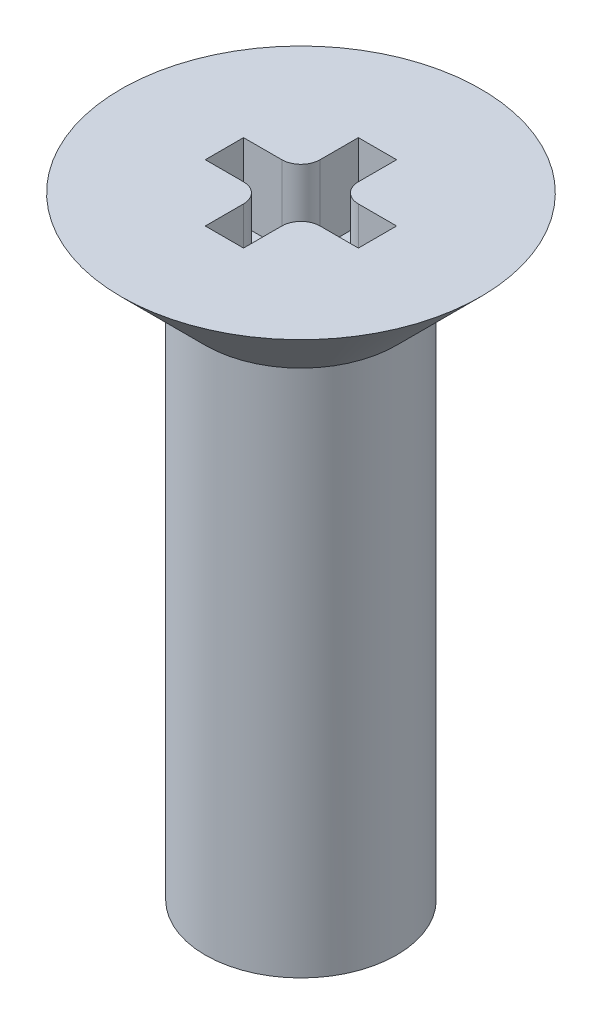
from build123d import *

# Parameters (mm, degrees)
SKETCH2_R           = 1.25
BOSS_EXTRUDE1_DEPTH = 6.5
CUT_EXTRUDE1_DEPTH  = 1


with BuildPart() as part:
    # Sketch1 → Revolve1 (revolve)
    with BuildSketch(Plane(origin=(0, 0, 0), x_dir=(0, 0, -1), z_dir=(1, 0, 0))):
        Polygon((0, 0), (-2.35, 0), (-1.25, -1.1), (-1.25, -1.5), (0, -1.5), align=None)
    revolve(axis=Axis((0, 0.872326939, 0), (0, -1, 0)))

    # Sketch2 → Boss-Extrude1 (add)
    with BuildSketch(Plane.XZ.offset(1.5)):
        Circle(SKETCH2_R)
    extrude(amount=BOSS_EXTRUDE1_DEPTH)

    # Sketch3 → Cut-Extrude1 (cut)
    with BuildSketch(Plane(origin=(0, 0, 0), x_dir=(1, 0, 0), z_dir=(0, 1, 0))):
        with BuildLine():
            Line((-1, -0.25), (-0.5, -0.25))
            ThreePointArc((-0.5, -0.25), (-0.323223305, -0.323223305), (-0.25, -0.5))
            Line((-0.25, -0.5), (-0.25, -1))
            Line((-0.25, -1), (0.25, -1))
            Line((0.25, -1), (0.25, -0.5))
            ThreePointArc((0.25, -0.5), (0.323223305, -0.323223305), (0.5, -0.25))
            Line((0.5, -0.25), (1, -0.25))
            Line((1, -0.25), (1, 0.25))
            Line((1, 0.25), (0.5, 0.25))
            ThreePointArc((0.5, 0.25), (0.323223305, 0.323223305), (0.25, 0.5))
            Line((0.25, 0.5), (0.25, 1))
            Line((0.25, 1), (-0.25, 1))
            Line((-0.25, 1), (-0.25, 0.5))
            ThreePointArc((-0.25, 0.5), (-0.323223305, 0.323223305), (-0.5, 0.25))
            Line((-0.5, 0.25), (-1, 0.25))
            Line((-1, 0.25), (-1, -0.25))
        make_face()
    extrude(amount=-CUT_EXTRUDE1_DEPTH, mode=Mode.SUBTRACT)


solid = part.part
